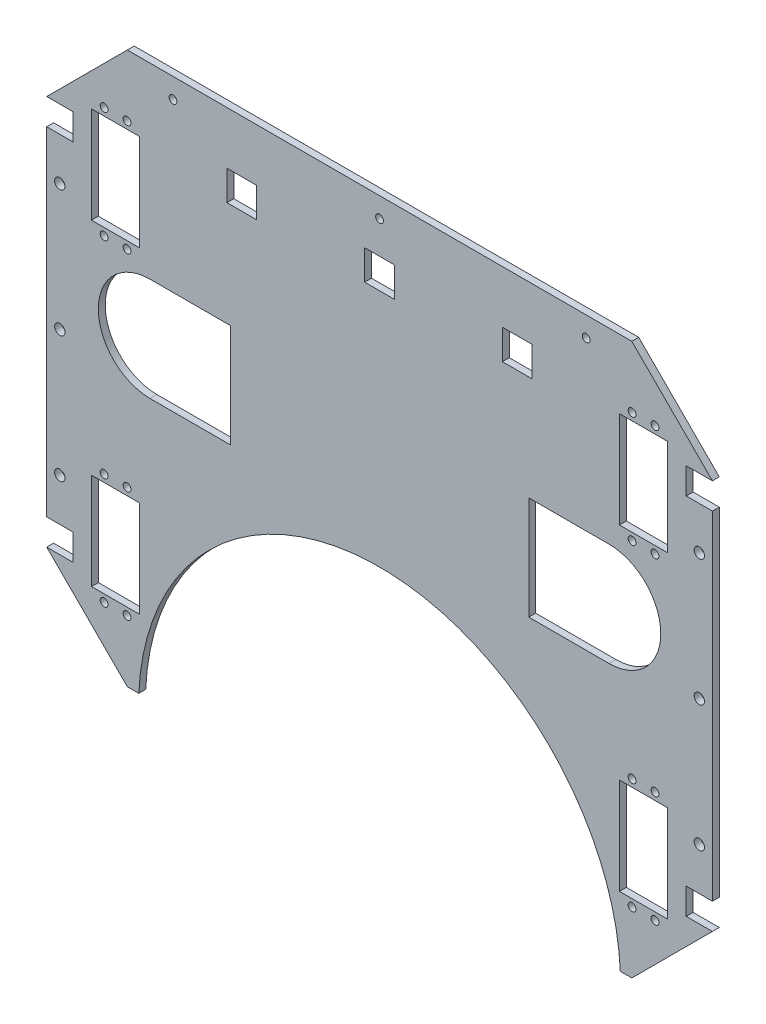
from build123d import *

# Parameters (mm, degrees)
BOSS_EXTRU_1_DEPTH           = 3
ESQUISSE26_W                 = 21
ESQUISSE26_H                 = 42
ENL_V_MAT_EXTRU_1_DEPTH      = 189.31174658
ESQUISSE21_W                 = 11.4
ESQUISSE21_H                 = 11.4
ENL_V_MAT_EXTRU_3_DEPTH      = 189.31174658
D_GAGEMENT_M32_D             = 3.4
D_GAGEMENT_M33_D             = 3.4
ENL_V_MAT_EXTRU_4_DEPTH      = 10
ENL_V_MAT_EXTRU_4_DEPTH_BACK = 189.31174658
D_GAGEMENT_M41_D             = 4.5
ESQUISSE40_W                 = 13
ESQUISSE40_H                 = 13
ENL_V_MAT_EXTRU_5_DEPTH      = 189.31174658


with BuildPart() as part:
    # Esquisse1 → Boss.-Extru.1 (new body)
    with BuildSketch(Plane.XY):
        with BuildLine():
            Line((-145, 85), (-109.886246, 120.113754))
            Line((-109.886246, 120.113754), (109.886246, 120.113754))
            Line((109.886246, 120.113754), (145, 85))
            Line((145, 85), (145, -85))
            Line((145, -85), (109.886246, -120.113754))
            Line((109.886246, -120.113754), (104.886246, -120.113754))
            ThreePointArc((104.886246, -120.113754), (0, -20), (-104.886246, -120.113754))
            Line((-104.886246, -120.113754), (-109.886246, -120.113754))
            Line((-109.886246, -120.113754), (-145, -85))
            Line((-145, -85), (-145, 85))
        make_face()
    extrude(amount=BOSS_EXTRU_1_DEPTH)

    # Esquisse26 → Enlèv. mat.-Extru.1 (cut, through all)
    with BuildSketch(Plane.XY.offset(3)):
        with Locations((-115, -69.113754)):
            Rectangle(ESQUISSE26_W, ESQUISSE26_H)
        with Locations((-115, 69.113754)):
            Rectangle(ESQUISSE26_W, ESQUISSE26_H)
        with Locations((115, 69.113754)):
            Rectangle(ESQUISSE26_W, ESQUISSE26_H)
        with Locations((115, -69.113754)):
            Rectangle(ESQUISSE26_W, ESQUISSE26_H)
    extrude(amount=-ENL_V_MAT_EXTRU_1_DEPTH, mode=Mode.SUBTRACT)

    # Esquisse21 → Enlèv. mat.-Extru.3 (cut, through all)
    with BuildSketch(Plane.XY.offset(3)):
        with Locations((-139.3, 79.3)):
            Rectangle(ESQUISSE21_W, ESQUISSE21_H)
        with Locations((139.3, 79.3)):
            Rectangle(ESQUISSE21_W, ESQUISSE21_H)
        with Locations((-139.3, -79.3)):
            Rectangle(ESQUISSE21_W, ESQUISSE21_H)
        with Locations((139.3, -79.3)):
            Rectangle(ESQUISSE21_W, ESQUISSE21_H)
    extrude(amount=-ENL_V_MAT_EXTRU_3_DEPTH, mode=Mode.SUBTRACT)

    # Dégagement M32 (through all)
    with Locations(Plane.XY.offset(3)):
        with Locations((-120, 93.313754), (-110, 93.313754), (-120, 44.913754), (-110, 44.913754), (-120, -44.913754), (-110, -44.913754), (-120, -93.313754), (-110, -93.313754), (110, -93.313754), (120, -93.313754), (120, -44.913754), (110, -44.913754), (120, 44.913754), (110, 44.913754), (110, 93.313754), (120, 93.313754)):
            Hole(D_GAGEMENT_M32_D / 2)

    # Dégagement M33 (through all)
    with Locations(Plane.XY.offset(3)):
        with Locations((-90, 111.413754), (0, 111.413754), (90, 111.413754)):
            Hole(D_GAGEMENT_M33_D / 2)

    # Esquisse36 → Enlèv. mat.-Extru.4 (cut, two sides: drawn at the far end of the back side and taken through both)
    with BuildSketch(Plane.XY.offset(3).offset(-ENL_V_MAT_EXTRU_4_DEPTH_BACK)):
        with BuildLine():
            Line((-65, 38.586246), (-100, 38.586246))
            ThreePointArc((-100, 38.586246), (-122.5, 16.086246), (-100, -6.413754))
            Line((-100, -6.413754), (-65, -6.413754))
            Line((-65, -6.413754), (-65, 38.586246))
        make_face()
        with BuildLine():
            ThreePointArc((100, 38.586246), (122.5, 16.086246), (100, -6.413754))
            Line((100, -6.413754), (65, -6.413754))
            Line((65, -6.413754), (65, 38.586246))
            Line((65, 38.586246), (100, 38.586246))
        make_face()
    extrude(amount=ENL_V_MAT_EXTRU_4_DEPTH + ENL_V_MAT_EXTRU_4_DEPTH_BACK, mode=Mode.SUBTRACT)

    # Dégagement M41 (through all)
    with Locations(Plane(origin=(0, 0, 0), x_dir=(-1, 0, 0), z_dir=(0, 0, -1))):
        with Locations((-139.3, 55), (-139.3, 0), (-139.3, -55), (139.3, 55), (139.3, 0), (139.3, -55)):
            Hole(D_GAGEMENT_M41_D / 2)

    # Esquisse40 → Enlèv. mat.-Extru.5 (cut, through all)
    with BuildSketch(Plane.XY.offset(3)):
        with Locations((-60, 90.713754)):
            Rectangle(ESQUISSE40_W, ESQUISSE40_H)
        with Locations((0, 90.713754)):
            Rectangle(ESQUISSE40_W, ESQUISSE40_H)
        with Locations((60, 90.713754)):
            Rectangle(ESQUISSE40_W, ESQUISSE40_H)
    extrude(amount=-ENL_V_MAT_EXTRU_5_DEPTH, mode=Mode.SUBTRACT)


solid = part.part
